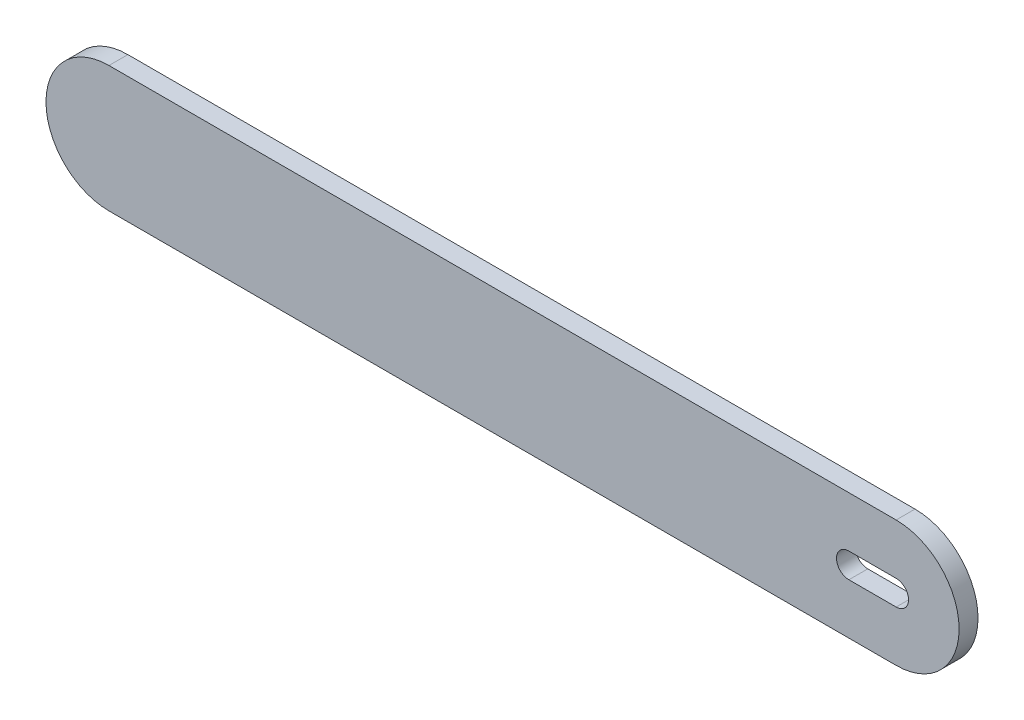
from build123d import *

# Parameters (mm, degrees)
BOSS_EXTRUDE1_DEPTH = 6
CUT_EXTRUDE1_REACH  = 8


with BuildPart() as part:
    # Sketch1 → Boss-Extrude1 (new body)
    with BuildSketch(Plane.XY):
        with BuildLine():
            Line((-53.14999664, -20.367507575), (-303.15, -20.367507575))
            ThreePointArc((-303.15, -20.367507575), (-323.15, -0.367507575), (-303.15, 19.632492425))
            Line((-303.15, 19.632492425), (-53.14999664, 19.632492425))
            ThreePointArc((-53.14999664, 19.632492425), (-33.15, -0.367507575), (-53.14999664, -20.367507575))
        make_face()
    extrude(amount=BOSS_EXTRUDE1_DEPTH)

    # Sketch2 → Cut-Extrude1 (cut, up to next)
    with BuildSketch(Plane(origin=(0, 0, 0), x_dir=(-1, 0, 0), z_dir=(0, 0, -1)), mode=Mode.PRIVATE) as cut_extrude1_sk1:
        with BuildLine():
            Line((53.15, 3.576263022), (68.15, 3.576263022))
            ThreePointArc((68.15, 3.576263022), (72.093770597, -0.367507575), (68.15, -4.311278172))
            Line((68.15, -4.311278172), (53.15, -4.311278172))
            ThreePointArc((53.15, -4.311278172), (49.206229403, -0.367507575), (53.15, 3.576263022))
        make_face()
    cut_extrude1_tool1 = extrude(cut_extrude1_sk1.sketch, amount=-CUT_EXTRUDE1_REACH, mode=Mode.PRIVATE) & part.part
    add(cut_extrude1_tool1.solids().sort_by_distance((-60.65, -0.367508, 0))[0], mode=Mode.SUBTRACT)


solid = part.part
